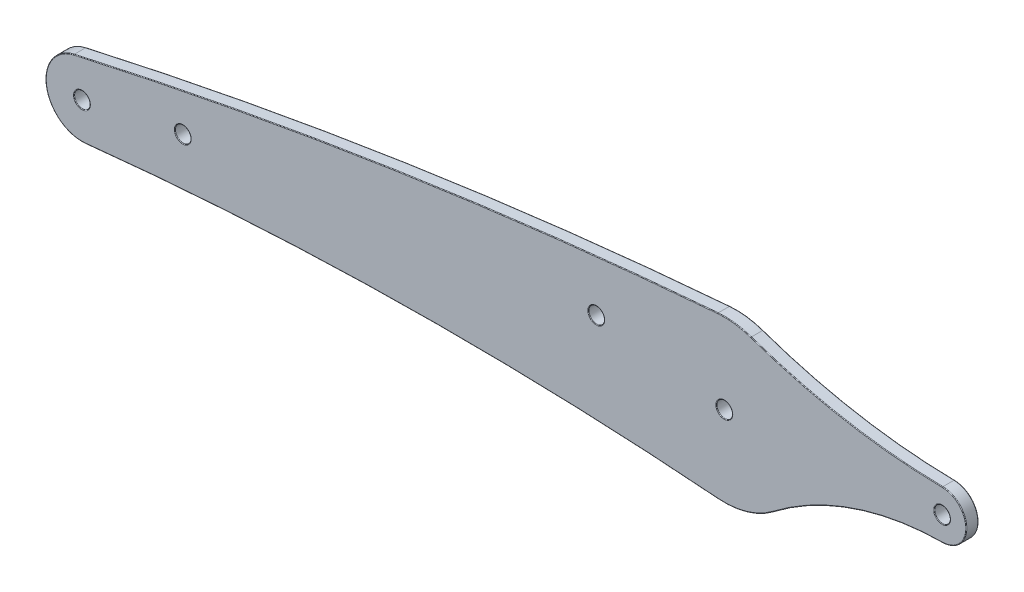
from build123d import *

# Parameters (mm, degrees)
DODANIE_WYCI_GNI_CIE1_DEPTH = 3
OTW_R_POD_RUB_M3_51_D       = 3.9
OTW_R_POD_RUB_M3_51_DEPTH   = 10
OTW_R_POD_RUB_M3_51_TIP     = 1.171678207
ZAOKR_GLENIE1_R             = 0.15


with BuildPart() as part:
    # Szkic2 → Dodanie-wyciągnięcie1 (new body)
    with BuildSketch(Plane.XY):
        with BuildLine():
            ThreePointArc((-213.918209682, 197.62531581), (-134.525874476, 212.575176987), (-54.279861598, 221.914269865))
            ThreePointArc((-54.279861598, 221.914269865), (-50.111308046, 221.815433396), (-46.053844528, 220.854393765))
            ThreePointArc((-46.053844528, 220.854393765), (-22.658520339, 214.723362786), (1.418023546, 212.431907063))
            ThreePointArc((1.418023546, 212.431907063), (7.332901497, 206.413727957), (1.380460775, 200.43269875))
            ThreePointArc((1.380460775, 200.43269875), (-20.741779779, 196.660001734), (-40.533281296, 186.080623794))
            ThreePointArc((-40.533281296, 186.080623794), (-47.012912361, 182.795282077), (-54.23859653, 182.041241475))
            ThreePointArc((-54.23859653, 182.041241475), (-132.664162133, 184.589715081), (-210.99057003, 179.89526263))
            ThreePointArc((-210.99057003, 179.89526263), (-220.822867576, 187.378461035), (-213.918209682, 197.62531581))
        make_face()
    extrude(amount=-DODANIE_WYCI_GNI_CIE1_DEPTH)

    # Otwór pod śrubę M3.51
    with Locations(Plane.XY):
        with Locations((-211.943109466, 188.844713374), (-186.943109466, 193.964215329), (-84.417069104, 206.371027022), (-52.667069104, 201.979403415), (1.332930896, 206.43251049)):
            Hole(OTW_R_POD_RUB_M3_51_D / 2, depth=OTW_R_POD_RUB_M3_51_DEPTH)
            with Locations((0, 0, -(OTW_R_POD_RUB_M3_51_DEPTH + OTW_R_POD_RUB_M3_51_TIP / 2))):  # 118° drill point
                Cone(0, OTW_R_POD_RUB_M3_51_D / 2, OTW_R_POD_RUB_M3_51_TIP, mode=Mode.SUBTRACT)

    # Zaokrąglenie1
    zaokr_glenie1_edges = [part.edges().sort_by_distance(p)[0] for p in [
        (-47.012912361, 182.795282077, -3),
        (-132.664162133, 184.589715081, 0),
        (-220.822867576, 187.378461035, 0),
        (-20.741779779, 196.660001734, -3),
        (7.332901497, 206.413727957, -3),
        (-22.658520339, 214.723362786, -3),
        (-50.111308046, 221.815433396, -3),
        (-134.525874476, 212.575176987, -3),
        (3.282930896, 206.43251049, -3),
        (3.282930896, 206.43251049, 0),
        (-50.717069104, 201.979403415, -3),
        (-50.717069104, 201.979403415, 0),
        (-82.467069104, 206.371027022, -3),
        (-82.467069104, 206.371027022, 0),
        (-220.822867576, 187.378461035, -3),
        (-184.993109466, 193.964215329, -3),
        (-184.993109466, 193.964215329, 0),
        (-209.993109466, 188.844713374, -3),
        (-209.993109466, 188.844713374, 0),
        (-132.664162133, 184.589715081, -3),
        (-134.525874476, 212.575176987, 0),
        (-50.111308046, 221.815433396, 0),
        (-22.658520339, 214.723362786, 0),
        (7.332901497, 206.413727957, 0),
        (-20.741779779, 196.660001734, 0),
        (-47.012912361, 182.795282077, 0),
    ]]
    fillet(zaokr_glenie1_edges, radius=ZAOKR_GLENIE1_R)


solid = part.part
